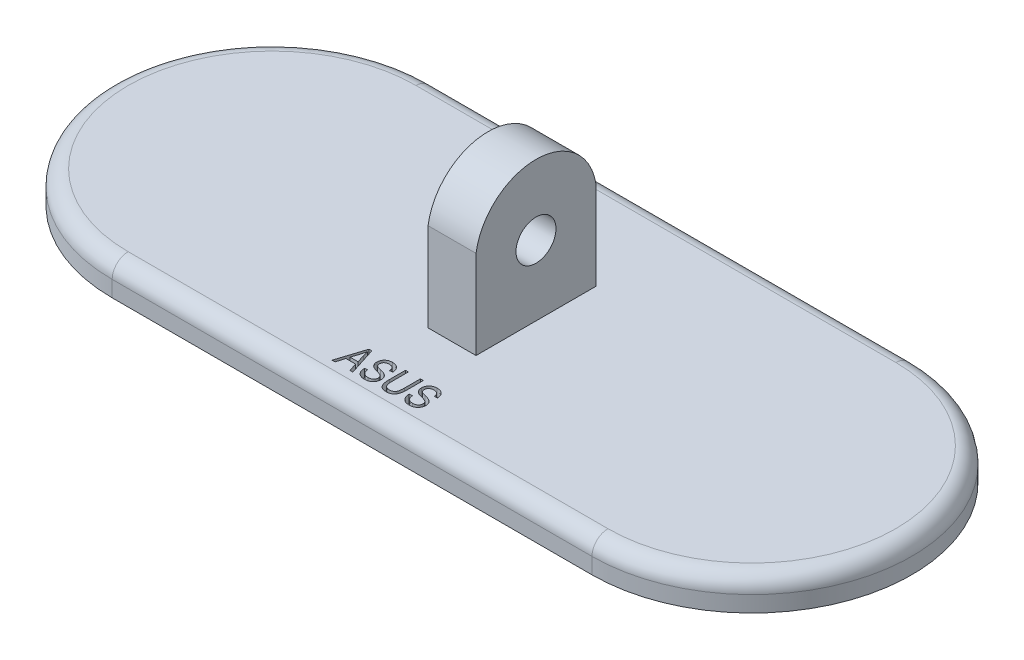
from build123d import *

# Parameters (mm, degrees)
BOSS_EXTRUDE1_DEPTH = 4
FILLET1_R           = 2
CUT_EXTRUDE1_DEPTH  = 1
SKETCH3_W           = 6
SKETCH3_H           = 15
BOSS_EXTRUDE2_DEPTH = 17.5
SKETCH4_R           = 2.5
CUT_EXTRUDE2_DEPTH  = 54


with BuildPart() as part:
    # Sketch1 → Boss-Extrude1 (new body)
    with BuildSketch(Plane(origin=(0, 0, 0), x_dir=(1, 0, 0), z_dir=(0, 1, 0))):
        with BuildLine():
            Line((-30, 20), (30, 20))
            ThreePointArc((30, 20), (50, 0), (30, -20))
            Line((30, -20), (-30, -20))
            ThreePointArc((-30, -20), (-50, 0), (-30, 20))
        make_face()
    extrude(amount=BOSS_EXTRUDE1_DEPTH)

    # Fillet1
    fillet1_edges = [part.edges().sort_by_distance(p)[0] for p in [
        (50, 4, 0),
        (0, 4, -20),
        (-50, 4, 0),
        (0, 4, 20),
    ]]
    fillet(fillet1_edges, radius=FILLET1_R)

    # Sketch2 → Cut-Extrude1 (cut)
    with BuildSketch(Plane(origin=(0, 4, 0), x_dir=(1, 0, 0), z_dir=(0, 1, 0))):
        Polygon((-5.5, -17), (-4.382102273, -13.5), (-4.027698864, -13.5), (-2.909090909, -17), (-3.286931818, -17), (-3.593039773, -15.954545455), (-4.816051136, -15.954545455), (-5.121448864, -17), align=None)
        with BuildLine():
            Line((-4.696732955, -15.545454545), (-3.713068182, -15.545454545))
            Line((-3.713068182, -15.545454545), (-4.005681818, -14.583806818))
            add(Edge.make_bspline(
                [(-4.005681818, -14.583806818), (-4.016628568, -14.547838767), (-4.0380005, -14.477616389), (-4.068265106, -14.374789216), (-4.09731225, -14.277259564), (-4.122124108, -14.184347112), (-4.146796541, -14.097260742), (-4.168074835, -14.015031326), (-4.18717565, -13.938066961), (-4.198909027, -13.888268538), (-4.204545455, -13.864346591)],
                knots=[0, 0, 0, 0, 0.00011279, 0.000220206, 0.000321569, 0.000418058, 0.000508692, 0.000593102, 0.000672856, 0.000746587, 0.000746587, 0.000746587, 0.000746587], degree=3))
            add(Edge.make_bspline(
                [(-4.204545455, -13.864346591), (-4.214778004, -13.920067319), (-4.235229509, -14.031434756), (-4.27356505, -14.197337197), (-4.316214502, -14.36294026), (-4.350161894, -14.472194468), (-4.3671875, -14.526988636)],
                knots=[0, 0, 0, 0, 0.000169936, 0.000339646, 0.000510706, 0.000682816, 0.000682816, 0.000682816, 0.000682816], degree=3))
            Line((-4.3671875, -14.526988636), (-4.696732955, -15.545454545))
        make_face(mode=Mode.SUBTRACT)
        with BuildLine():
            Line((-2.590909091, -15.863636364), (-2.227272727, -15.818181818))
            add(Edge.make_bspline(
                [(-2.227272727, -15.818181818), (-2.22197797, -15.864475668), (-2.211936421, -15.95227231), (-2.184434304, -16.075223938), (-2.147650136, -16.182043631), (-2.102205699, -16.274883356), (-2.043969166, -16.353580019), (-1.977448033, -16.424354515), (-1.899095683, -16.486099213), (-1.811387696, -16.540002711), (-1.714850911, -16.58350722), (-1.611278133, -16.613567605), (-1.502131405, -16.632807195), (-1.427403021, -16.63516064), (-1.389204545, -16.636363636)],
                knots=[0, 0, 0, 0, 0.00013972, 0.00026498, 0.000377063, 0.000478068, 0.000573677, 0.000669632, 0.000768682, 0.000871976, 0.000977838, 0.001085254, 0.001194776, 0.001309301, 0.001309301, 0.001309301, 0.001309301], degree=3))
            add(Edge.make_bspline(
                [(-1.389204545, -16.636363636), (-1.361956661, -16.635809911), (-1.309002617, -16.634733791), (-1.231895402, -16.626639835), (-1.159268353, -16.61444724), (-1.091804433, -16.595479121), (-1.028249477, -16.573297881), (-0.970392644, -16.543725979), (-0.91625106, -16.510305453), (-0.867397151, -16.471395087), (-0.824318723, -16.42766111), (-0.785271107, -16.3817624), (-0.753522436, -16.331514605), (-0.726751017, -16.278898951), (-0.707118518, -16.222620133), (-0.691891008, -16.163798809), (-0.683401716, -16.10133582), (-0.6823543, -16.058736303), (-0.681818182, -16.036931818)],
                knots=[0, 0, 0, 0, 8.1726e-05, 0.000158827, 0.000232389, 0.000302342, 0.000368846, 0.000433959, 0.000496821, 0.00055949, 0.00062076, 0.000680777, 0.00073988, 0.00079864, 0.000857499, 0.000918305, 0.00098068, 0.001046083, 0.001046083, 0.001046083, 0.001046083], degree=3))
            add(Edge.make_bspline(
                [(-0.681818182, -16.036931818), (-0.682599913, -16.011783639), (-0.684122535, -15.962801096), (-0.697082564, -15.891495502), (-0.71918005, -15.825416047), (-0.749262653, -15.764056888), (-0.788115011, -15.707910777), (-0.836096444, -15.65725245), (-0.893110954, -15.612473062), (-0.947513747, -15.578513088), (-1.000067739, -15.553778017), (-1.049719672, -15.532456693), (-1.109516389, -15.509966234), (-1.179361005, -15.485759378), (-1.259275635, -15.460541052), (-1.349304319, -15.433520449), (-1.449132376, -15.404343325), (-1.519382908, -15.385073654), (-1.556107955, -15.375)],
                knots=[0, 0, 0, 0, 7.5405e-05, 0.00014687, 0.000216494, 0.000283831, 0.000351209, 0.000420542, 0.000492307, 0.000568195, 0.000612349, 0.000666439, 0.00073028, 0.000803952, 0.000888182, 0.000981652, 0.001085942, 0.001200185, 0.001200185, 0.001200185, 0.001200185], degree=3))
            add(Edge.make_bspline(
                [(-1.556107955, -15.375), (-1.589066208, -15.365700823), (-1.652581841, -15.347779877), (-1.743664959, -15.319099389), (-1.82756541, -15.291259739), (-1.903766036, -15.261557906), (-1.97322383, -15.233349826), (-2.034571413, -15.203078327), (-2.088748272, -15.173437558), (-2.151054144, -15.134115412), (-2.219107276, -15.079119687), (-2.291234164, -15.005632486), (-2.354241661, -14.924260179), (-2.406810118, -14.835009875), (-2.449445591, -14.738977453), (-2.477677497, -14.635461447), (-2.497368172, -14.526552275), (-2.499111693, -14.451560064), (-2.5, -14.413352273)],
                knots=[0, 0, 0, 0, 0.000102728, 0.000197973, 0.000286464, 0.000367846, 0.000443294, 0.000511268, 0.00057294, 0.000628501, 0.000732099, 0.000834554, 0.000936837, 0.001040006, 0.001144643, 0.001250981, 0.001361203, 0.001475691, 0.001475691, 0.001475691, 0.001475691], degree=3))
            add(Edge.make_bspline(
                [(-2.5, -14.413352273), (-2.499216155, -14.378981672), (-2.497675273, -14.311415996), (-2.48452108, -14.21252492), (-2.463670739, -14.118103929), (-2.432557894, -14.0291615), (-2.394492747, -13.944430912), (-2.346286998, -13.86561284), (-2.29054503, -13.790818473), (-2.226008678, -13.721825566), (-2.154927099, -13.658551838), (-2.076487147, -13.604167759), (-1.992344651, -13.558082631), (-1.902482024, -13.519144857), (-1.806073101, -13.490352621), (-1.70403432, -13.470085913), (-1.596229432, -13.456768002), (-1.522294789, -13.455298921), (-1.484375, -13.454545455)],
                knots=[0, 0, 0, 0, 0.000103071, 0.000202617, 0.000298758, 0.000392642, 0.000484808, 0.000576891, 0.000669221, 0.000764203, 0.000859812, 0.000954187, 0.001049867, 0.001147228, 0.001247433, 0.001351063, 0.001459067, 0.001572783, 0.001572783, 0.001572783, 0.001572783], degree=3))
            add(Edge.make_bspline(
                [(-1.484375, -13.454545455), (-1.432677728, -13.45598872), (-1.331802768, -13.458804911), (-1.185476907, -13.482357844), (-1.049209402, -13.522259425), (-0.923518284, -13.577783176), (-0.809384889, -13.64787809), (-0.70876681, -13.732969255), (-0.620986799, -13.83115362), (-0.547962226, -13.94348761), (-0.48885885, -14.067402867), (-0.445580032, -14.202351051), (-0.417364879, -14.347607584), (-0.411900071, -14.448260029), (-0.409090909, -14.5)],
                knots=[0, 0, 0, 0, 0.000155027, 0.000302497, 0.00044318, 0.000579906, 0.000713536, 0.000843575, 0.000973865, 0.001107225, 0.001244144, 0.00138452, 0.001531332, 0.001686632, 0.001686632, 0.001686632, 0.001686632], degree=3))
            Line((-0.409090909, -14.5), (-0.772727273, -14.545454545))
            add(Edge.make_bspline(
                [(-0.772727273, -14.545454545), (-0.775394829, -14.517465857), (-0.78059677, -14.462885754), (-0.794969804, -14.384369508), (-0.813340355, -14.311163279), (-0.836372331, -14.243667328), (-0.865313417, -14.182131625), (-0.897535728, -14.125856233), (-0.935067643, -14.075422649), (-0.976941819, -14.030554018), (-1.023617894, -13.991261992), (-1.074471085, -13.956823707), (-1.129933758, -13.92765352), (-1.190104526, -13.904403902), (-1.254200278, -13.88569656), (-1.323001043, -13.873254871), (-1.396120547, -13.865306245), (-1.44647448, -13.864202485), (-1.472301136, -13.863636364)],
                knots=[0, 0, 0, 0, 8.4314e-05, 0.000164419, 0.000239178, 0.000310605, 0.000377968, 0.000442894, 0.000504827, 0.000566129, 0.000626603, 0.000687471, 0.000750056, 0.000814154, 0.000880688, 0.000950058, 0.001023627, 0.001101094, 0.001101094, 0.001101094, 0.001101094], degree=3))
            add(Edge.make_bspline(
                [(-1.472301136, -13.863636364), (-1.498607438, -13.863861681), (-1.549453941, -13.864297189), (-1.623406585, -13.872887979), (-1.692655981, -13.884233611), (-1.757296118, -13.901510812), (-1.816769957, -13.923315067), (-1.871904917, -13.949937896), (-1.921952204, -13.98162392), (-1.967182833, -14.018158832), (-2.006793971, -14.058783954), (-2.041640788, -14.101989157), (-2.071441238, -14.14794147), (-2.094667727, -14.197334209), (-2.113216893, -14.249432927), (-2.126849375, -14.30434261), (-2.134613493, -14.362230747), (-2.135772497, -14.40172917), (-2.136363636, -14.421875)],
                knots=[0, 0, 0, 0, 7.8864e-05, 0.000152433, 0.000223075, 0.000289229, 0.000352821, 0.000412856, 0.000472557, 0.000530125, 0.000586876, 0.000642447, 0.000696429, 0.000750751, 0.000805788, 0.000862115, 0.000920172, 0.000980608, 0.000980608, 0.000980608, 0.000980608], degree=3))
            add(Edge.make_bspline(
                [(-2.136363636, -14.421875), (-2.135158731, -14.45798656), (-2.132867659, -14.526651015), (-2.111448499, -14.623379604), (-2.075796294, -14.708163084), (-2.039637016, -14.754438968), (-2.022017045, -14.776988636)],
                knots=[0, 0, 0, 0, 0.000108188, 0.000205714, 0.000295712, 0.000381246, 0.000381246, 0.000381246, 0.000381246], degree=3))
            add(Edge.make_bspline(
                [(-2.022017045, -14.776988636), (-2.011198317, -14.787776882), (-1.9877006, -14.811208391), (-1.942444803, -14.840729621), (-1.888574861, -14.871786928), (-1.823291732, -14.899954833), (-1.748974666, -14.929489673), (-1.663747273, -14.956567477), (-1.568690497, -14.984584049), (-1.501258395, -15.001221491), (-1.465909091, -15.009943182)],
                knots=[0, 0, 0, 0, 4.5726e-05, 9.9314e-05, 0.000161332, 0.000232219, 0.000312277, 0.000401217, 0.000500336, 0.000609547, 0.000609547, 0.000609547, 0.000609547], degree=3))
            add(Edge.make_bspline(
                [(-1.465909091, -15.009943182), (-1.431077929, -15.018346165), (-1.364149902, -15.034492485), (-1.268169823, -15.059674797), (-1.179994991, -15.08295157), (-1.099756372, -15.10524418), (-1.028011119, -15.128309894), (-0.964125593, -15.149694435), (-0.907736501, -15.168790827), (-0.873737122, -15.183508799), (-0.857954545, -15.190340909)],
                knots=[0, 0, 0, 0, 0.000107489, 0.000206539, 0.000297673, 0.000381084, 0.000456332, 0.00052371, 0.000583238, 0.000634811, 0.000634811, 0.000634811, 0.000634811], degree=3))
            add(Edge.make_bspline(
                [(-0.857954545, -15.190340909), (-0.815377436, -15.210934727), (-0.732828012, -15.250862467), (-0.622785718, -15.329127409), (-0.528537774, -15.418058059), (-0.451846413, -15.519626488), (-0.39131779, -15.631595197), (-0.348919538, -15.754406993), (-0.322681069, -15.887146792), (-0.319709386, -15.979040994), (-0.318181818, -16.026278409)],
                knots=[0, 0, 0, 0, 0.000141677, 0.000274687, 0.000403287, 0.000529, 0.000654836, 0.000783544, 0.000917401, 0.001058993, 0.001058993, 0.001058993, 0.001058993], degree=3))
            add(Edge.make_bspline(
                [(-0.318181818, -16.026278409), (-0.31972652, -16.073750592), (-0.322778709, -16.167551257), (-0.349868593, -16.304755054), (-0.394130686, -16.435506064), (-0.45604135, -16.557681782), (-0.531806561, -16.670166003), (-0.620965754, -16.769947813), (-0.723916748, -16.854586795), (-0.839214384, -16.924475739), (-0.966866875, -16.979929102), (-1.107423102, -17.017296176), (-1.25981861, -17.041488087), (-1.365667813, -17.044101739), (-1.420454545, -17.045454545)],
                knots=[0, 0, 0, 0, 0.000142301, 0.000281173, 0.000417729, 0.000555261, 0.000690788, 0.000823556, 0.000955232, 0.001089096, 0.001226838, 0.001371229, 0.001524313, 0.001688561, 0.001688561, 0.001688561, 0.001688561], degree=3))
            add(Edge.make_bspline(
                [(-1.420454545, -17.045454545), (-1.463586734, -17.044550108), (-1.547753562, -17.042785216), (-1.670414663, -17.02758813), (-1.786247482, -17.002861618), (-1.895510013, -16.968015361), (-1.99836682, -16.923098139), (-2.094705237, -16.868313788), (-2.184047093, -16.803281539), (-2.265688913, -16.728457073), (-2.339520768, -16.645438235), (-2.404578332, -16.554918234), (-2.45960944, -16.456679389), (-2.504675468, -16.351522783), (-2.541329303, -16.239636899), (-2.568132253, -16.120769487), (-2.585265411, -15.99454887), (-2.58899827, -15.907960336), (-2.590909091, -15.863636364)],
                knots=[0, 0, 0, 0, 0.000129357, 0.000252423, 0.000370135, 0.000484236, 0.000595868, 0.000706249, 0.000816061, 0.000926661, 0.00103784, 0.001148804, 0.00126042, 0.001374941, 0.001491507, 0.001613147, 0.001740007, 0.001873049, 0.001873049, 0.001873049, 0.001873049], degree=3))
        make_face()
        with BuildLine():
            Line((2.045454545, -13.5), (2.409090909, -13.5))
            Line((2.409090909, -13.5), (2.409090909, -15.514204545))
            add(Edge.make_bspline(
                [(2.409090909, -15.514204545), (2.408923356, -15.555405357), (2.408595821, -15.635945022), (2.402965162, -15.754077177), (2.39653413, -15.866642424), (2.385857462, -15.973502622), (2.371597883, -16.074388511), (2.354581543, -16.169872597), (2.334896815, -16.25972689), (2.312330896, -16.344322046), (2.285343361, -16.423700996), (2.253194639, -16.498690113), (2.21637291, -16.569406789), (2.175188431, -16.636533443), (2.127211154, -16.697887468), (2.075071296, -16.755868641), (2.018444763, -16.809997481), (1.956298927, -16.859034292), (1.889812575, -16.903294034), (1.818054958, -16.940668757), (1.742868801, -16.973811945), (1.662600709, -16.999868994), (1.578360136, -17.020602312), (1.489443461, -17.034265103), (1.396529012, -17.044163368), (1.33288793, -17.045018409), (1.300426136, -17.045454545)],
                knots=[0, 0, 0, 0, 0.000123588, 0.00024159, 0.000354739, 0.000461805, 0.000563653, 0.000660337, 0.000752703, 0.000839536, 0.000922863, 0.001003997, 0.001084048, 0.001161892, 0.001239881, 0.001317325, 0.001395695, 0.001474559, 0.001554535, 0.001634916, 0.001716984, 0.001800757, 0.001887748, 0.001976954, 0.002070451, 0.002167793, 0.002167793, 0.002167793, 0.002167793], degree=3))
            add(Edge.make_bspline(
                [(1.300426136, -17.045454545), (1.255150549, -17.044694832), (1.167123779, -17.043217763), (1.039764185, -17.026228874), (0.920907741, -17.000444833), (0.810757778, -16.963469474), (0.709484059, -16.915766851), (0.616495335, -16.857900263), (0.53330225, -16.788476176), (0.457845097, -16.708456951), (0.391456252, -16.614302428), (0.335052614, -16.504173539), (0.28811466, -16.378041606), (0.248102928, -16.236598943), (0.218235521, -16.078756397), (0.197767834, -15.904785072), (0.183735999, -15.714952942), (0.182474335, -15.582887657), (0.181818182, -15.514204545)],
                knots=[0, 0, 0, 0, 0.000135744, 0.00026392, 0.000384711, 0.000500153, 0.000611668, 0.000719851, 0.000827792, 0.000935823, 0.001048935, 0.001172187, 0.001305938, 0.00145208, 0.00161268, 0.001787281, 0.001977391, 0.002183401, 0.002183401, 0.002183401, 0.002183401], degree=3))
            Line((0.181818182, -15.514204545), (0.181818182, -13.5))
            Line((0.181818182, -13.5), (0.545454545, -13.5))
            Line((0.545454545, -13.5), (0.545454545, -15.516335227))
            add(Edge.make_bspline(
                [(0.545454545, -15.516335227), (0.54576398, -15.55445341), (0.546361846, -15.628102411), (0.549878972, -15.734433564), (0.555551893, -15.832709771), (0.562931833, -15.922792134), (0.573655698, -16.004508095), (0.586284195, -16.078007075), (0.601078482, -16.143480587), (0.622902505, -16.218960871), (0.659507492, -16.301962092), (0.714489996, -16.390315237), (0.782017827, -16.465751895), (0.861012008, -16.528282263), (0.951010353, -16.576875772), (1.05026813, -16.611457225), (1.158684115, -16.632541867), (1.233802619, -16.635059209), (1.272727273, -16.636363636)],
                knots=[0, 0, 0, 0, 0.000114355, 0.000220949, 0.000319125, 0.000409661, 0.000492029, 0.000566291, 0.000633313, 0.000693313, 0.000801774, 0.000904236, 0.001004328, 0.001103934, 0.001204999, 0.001309675, 0.001418182, 0.001534875, 0.001534875, 0.001534875, 0.001534875], degree=3))
            add(Edge.make_bspline(
                [(1.272727273, -16.636363636), (1.305429116, -16.635724682), (1.368885859, -16.634484814), (1.460392807, -16.623763121), (1.545256708, -16.606367021), (1.622730089, -16.580587787), (1.693757602, -16.548770415), (1.757893228, -16.509566777), (1.814000439, -16.462138347), (1.86483847, -16.407855638), (1.907875946, -16.341897076), (1.945584423, -16.263971557), (1.976093475, -16.171850761), (2.002310261, -16.066974967), (2.021672499, -15.948165084), (2.035481282, -15.816324419), (2.044027275, -15.670803113), (2.044964436, -15.56937791), (2.045454545, -15.516335227)],
                knots=[0, 0, 0, 0, 9.8076e-05, 0.000190312, 0.000275979, 0.000357507, 0.000434743, 0.000509049, 0.000582161, 0.000654541, 0.000731364, 0.000817445, 0.000913576, 0.001021924, 0.001141487, 0.001274351, 0.001419488, 0.001578604, 0.001578604, 0.001578604, 0.001578604], degree=3))
            Line((2.045454545, -15.516335227), (2.045454545, -13.5))
        make_face()
        with BuildLine():
            Line((3, -15.863636364), (3.363636364, -15.818181818))
            add(Edge.make_bspline(
                [(3.363636364, -15.818181818), (3.368931121, -15.864475668), (3.37897267, -15.95227231), (3.406474787, -16.075223938), (3.443258955, -16.182043631), (3.488703392, -16.274883356), (3.546939925, -16.353580019), (3.613461058, -16.424354515), (3.691813407, -16.486099213), (3.779521395, -16.540002711), (3.87605818, -16.58350722), (3.979630958, -16.613567605), (4.088777686, -16.632807195), (4.16350607, -16.63516064), (4.201704545, -16.636363636)],
                knots=[0, 0, 0, 0, 0.00013972, 0.00026498, 0.000377063, 0.000478068, 0.000573677, 0.000669632, 0.000768682, 0.000871976, 0.000977838, 0.001085254, 0.001194776, 0.001309301, 0.001309301, 0.001309301, 0.001309301], degree=3))
            add(Edge.make_bspline(
                [(4.201704545, -16.636363636), (4.22895243, -16.635809911), (4.281906474, -16.634733791), (4.359013689, -16.626639835), (4.431640737, -16.61444724), (4.499104658, -16.595479121), (4.562659614, -16.573297881), (4.620516447, -16.543725979), (4.67465803, -16.510305453), (4.72351194, -16.471395087), (4.766590368, -16.42766111), (4.805637983, -16.3817624), (4.837386655, -16.331514605), (4.864158074, -16.278898951), (4.883790573, -16.222620133), (4.899018083, -16.163798809), (4.907507375, -16.10133582), (4.908554791, -16.058736303), (4.909090909, -16.036931818)],
                knots=[0, 0, 0, 0, 8.1726e-05, 0.000158827, 0.000232389, 0.000302342, 0.000368846, 0.000433959, 0.000496821, 0.00055949, 0.00062076, 0.000680777, 0.00073988, 0.00079864, 0.000857499, 0.000918305, 0.00098068, 0.001046083, 0.001046083, 0.001046083, 0.001046083], degree=3))
            add(Edge.make_bspline(
                [(4.909090909, -16.036931818), (4.908309178, -16.011783639), (4.906786556, -15.962801096), (4.893826527, -15.891495502), (4.871729041, -15.825416047), (4.841646438, -15.764056888), (4.80279408, -15.707910777), (4.754812647, -15.65725245), (4.697798137, -15.612473062), (4.643395344, -15.578513088), (4.590841352, -15.553778017), (4.541189419, -15.532456693), (4.481392702, -15.509966234), (4.411548086, -15.485759378), (4.331633456, -15.460541052), (4.241604772, -15.433520449), (4.141776715, -15.404343325), (4.071526182, -15.385073654), (4.034801136, -15.375)],
                knots=[0, 0, 0, 0, 7.5405e-05, 0.00014687, 0.000216494, 0.000283831, 0.000351209, 0.000420542, 0.000492307, 0.000568195, 0.000612349, 0.000666439, 0.00073028, 0.000803952, 0.000888182, 0.000981652, 0.001085942, 0.001200185, 0.001200185, 0.001200185, 0.001200185], degree=3))
            add(Edge.make_bspline(
                [(4.034801136, -15.375), (4.001842883, -15.365700823), (3.93832725, -15.347779877), (3.847244132, -15.319099389), (3.76334368, -15.291259739), (3.687143054, -15.261557906), (3.617685261, -15.233349826), (3.556337678, -15.203078327), (3.502160819, -15.173437558), (3.439854947, -15.134115412), (3.371801815, -15.079119687), (3.299674927, -15.005632486), (3.23666743, -14.924260179), (3.184098973, -14.835009875), (3.1414635, -14.738977453), (3.113231594, -14.635461447), (3.093540919, -14.526552275), (3.091797398, -14.451560064), (3.090909091, -14.413352273)],
                knots=[0, 0, 0, 0, 0.000102728, 0.000197973, 0.000286464, 0.000367846, 0.000443294, 0.000511268, 0.00057294, 0.000628501, 0.000732099, 0.000834554, 0.000936837, 0.001040006, 0.001144643, 0.001250981, 0.001361203, 0.001475691, 0.001475691, 0.001475691, 0.001475691], degree=3))
            add(Edge.make_bspline(
                [(3.090909091, -14.413352273), (3.091692936, -14.378981672), (3.093233818, -14.311415996), (3.106388011, -14.21252492), (3.127238351, -14.118103929), (3.158351197, -14.0291615), (3.196416344, -13.944430912), (3.244622093, -13.86561284), (3.300364061, -13.790818473), (3.364900413, -13.721825566), (3.435981992, -13.658551838), (3.514421944, -13.604167759), (3.59856444, -13.558082631), (3.688427067, -13.519144857), (3.78483599, -13.490352621), (3.886874771, -13.470085913), (3.994679659, -13.456768002), (4.068614302, -13.455298921), (4.106534091, -13.454545455)],
                knots=[0, 0, 0, 0, 0.000103071, 0.000202617, 0.000298758, 0.000392642, 0.000484808, 0.000576891, 0.000669221, 0.000764203, 0.000859812, 0.000954187, 0.001049867, 0.001147228, 0.001247433, 0.001351063, 0.001459067, 0.001572783, 0.001572783, 0.001572783, 0.001572783], degree=3))
            add(Edge.make_bspline(
                [(4.106534091, -13.454545455), (4.158231362, -13.45598872), (4.259106323, -13.458804911), (4.405432184, -13.482357844), (4.541699689, -13.522259425), (4.667390807, -13.577783176), (4.781524202, -13.64787809), (4.882142281, -13.732969255), (4.969922292, -13.83115362), (5.042946865, -13.94348761), (5.10205024, -14.067402867), (5.145329059, -14.202351051), (5.173544212, -14.347607584), (5.17900902, -14.448260029), (5.181818182, -14.5)],
                knots=[0, 0, 0, 0, 0.000155027, 0.000302497, 0.00044318, 0.000579906, 0.000713536, 0.000843575, 0.000973865, 0.001107225, 0.001244144, 0.00138452, 0.001531332, 0.001686632, 0.001686632, 0.001686632, 0.001686632], degree=3))
            Line((5.181818182, -14.5), (4.818181818, -14.545454545))
            add(Edge.make_bspline(
                [(4.818181818, -14.545454545), (4.815514262, -14.517465857), (4.810312321, -14.462885754), (4.795939287, -14.384369508), (4.777568736, -14.311163279), (4.75453676, -14.243667328), (4.725595674, -14.182131625), (4.693373363, -14.125856233), (4.655841448, -14.075422649), (4.613967272, -14.030554018), (4.567291197, -13.991261992), (4.516438006, -13.956823707), (4.460975333, -13.92765352), (4.400804565, -13.904403902), (4.336708813, -13.88569656), (4.267908048, -13.873254871), (4.194788543, -13.865306245), (4.144434611, -13.864202485), (4.118607955, -13.863636364)],
                knots=[0, 0, 0, 0, 8.4314e-05, 0.000164419, 0.000239178, 0.000310605, 0.000377968, 0.000442894, 0.000504827, 0.000566129, 0.000626603, 0.000687471, 0.000750056, 0.000814154, 0.000880688, 0.000950058, 0.001023627, 0.001101094, 0.001101094, 0.001101094, 0.001101094], degree=3))
            add(Edge.make_bspline(
                [(4.118607955, -13.863636364), (4.092301653, -13.863861681), (4.04145515, -13.864297189), (3.967502506, -13.872887979), (3.89825311, -13.884233611), (3.833612973, -13.901510812), (3.774139134, -13.923315067), (3.719004174, -13.949937896), (3.668956886, -13.98162392), (3.623726257, -14.018158832), (3.58411512, -14.058783954), (3.549268303, -14.101989157), (3.519467853, -14.14794147), (3.496241364, -14.197334209), (3.477692198, -14.249432927), (3.464059716, -14.30434261), (3.456295597, -14.362230747), (3.455136594, -14.40172917), (3.454545455, -14.421875)],
                knots=[0, 0, 0, 0, 7.8864e-05, 0.000152433, 0.000223075, 0.000289229, 0.000352821, 0.000412856, 0.000472557, 0.000530125, 0.000586876, 0.000642447, 0.000696429, 0.000750751, 0.000805788, 0.000862115, 0.000920172, 0.000980608, 0.000980608, 0.000980608, 0.000980608], degree=3))
            add(Edge.make_bspline(
                [(3.454545455, -14.421875), (3.45575036, -14.45798656), (3.458041432, -14.526651015), (3.479460592, -14.623379604), (3.515112797, -14.708163084), (3.551272075, -14.754438968), (3.568892045, -14.776988636)],
                knots=[0, 0, 0, 0, 0.000108188, 0.000205714, 0.000295712, 0.000381246, 0.000381246, 0.000381246, 0.000381246], degree=3))
            add(Edge.make_bspline(
                [(3.568892045, -14.776988636), (3.579710774, -14.787776882), (3.603208491, -14.811208391), (3.648464288, -14.840729621), (3.70233423, -14.871786928), (3.767617358, -14.899954833), (3.841934425, -14.929489673), (3.927161818, -14.956567477), (4.022218594, -14.984584049), (4.089650696, -15.001221491), (4.125, -15.009943182)],
                knots=[0, 0, 0, 0, 4.5726e-05, 9.9314e-05, 0.000161332, 0.000232219, 0.000312277, 0.000401217, 0.000500336, 0.000609547, 0.000609547, 0.000609547, 0.000609547], degree=3))
            add(Edge.make_bspline(
                [(4.125, -15.009943182), (4.159831162, -15.018346165), (4.226759189, -15.034492485), (4.322739268, -15.059674797), (4.4109141, -15.08295157), (4.491152719, -15.10524418), (4.562897972, -15.128309894), (4.626783498, -15.149694435), (4.68317259, -15.168790827), (4.717171969, -15.183508799), (4.732954545, -15.190340909)],
                knots=[0, 0, 0, 0, 0.000107489, 0.000206539, 0.000297673, 0.000381084, 0.000456332, 0.00052371, 0.000583238, 0.000634811, 0.000634811, 0.000634811, 0.000634811], degree=3))
            add(Edge.make_bspline(
                [(4.732954545, -15.190340909), (4.775531655, -15.210934727), (4.858081079, -15.250862467), (4.968123372, -15.329127409), (5.062371317, -15.418058059), (5.139062678, -15.519626488), (5.199591301, -15.631595197), (5.241989552, -15.754406993), (5.268228022, -15.887146792), (5.271199705, -15.979040994), (5.272727273, -16.026278409)],
                knots=[0, 0, 0, 0, 0.000141677, 0.000274687, 0.000403287, 0.000529, 0.000654836, 0.000783544, 0.000917401, 0.001058993, 0.001058993, 0.001058993, 0.001058993], degree=3))
            add(Edge.make_bspline(
                [(5.272727273, -16.026278409), (5.271182571, -16.073750592), (5.268130382, -16.167551257), (5.241040498, -16.304755054), (5.196778405, -16.435506064), (5.134867741, -16.557681782), (5.05910253, -16.670166003), (4.969943337, -16.769947813), (4.866992343, -16.854586795), (4.751694707, -16.924475739), (4.624042216, -16.979929102), (4.483485989, -17.017296176), (4.331090481, -17.041488087), (4.225241278, -17.044101739), (4.170454545, -17.045454545)],
                knots=[0, 0, 0, 0, 0.000142301, 0.000281173, 0.000417729, 0.000555261, 0.000690788, 0.000823556, 0.000955232, 0.001089096, 0.001226838, 0.001371229, 0.001524313, 0.001688561, 0.001688561, 0.001688561, 0.001688561], degree=3))
            add(Edge.make_bspline(
                [(4.170454545, -17.045454545), (4.127322357, -17.044550108), (4.043155529, -17.042785216), (3.920494428, -17.02758813), (3.804661609, -17.002861618), (3.695399078, -16.968015361), (3.592542271, -16.923098139), (3.496203854, -16.868313788), (3.406861998, -16.803281539), (3.325220178, -16.728457073), (3.251388323, -16.645438235), (3.186330758, -16.554918234), (3.131299651, -16.456679389), (3.086233623, -16.351522783), (3.049579788, -16.239636899), (3.022776838, -16.120769487), (3.00564368, -15.99454887), (3.001910821, -15.907960336), (3, -15.863636364)],
                knots=[0, 0, 0, 0, 0.000129357, 0.000252423, 0.000370135, 0.000484236, 0.000595868, 0.000706249, 0.000816061, 0.000926661, 0.00103784, 0.001148804, 0.00126042, 0.001374941, 0.001491507, 0.001613147, 0.001740007, 0.001873049, 0.001873049, 0.001873049, 0.001873049], degree=3))
        make_face()
    extrude(amount=-CUT_EXTRUDE1_DEPTH, mode=Mode.SUBTRACT)

    # Sketch3 → Boss-Extrude2 (add)
    with BuildSketch(Plane(origin=(0, 4, 0), x_dir=(1, 0, 0), z_dir=(0, 1, 0))):
        Rectangle(SKETCH3_W, SKETCH3_H)
    extrude(amount=BOSS_EXTRUDE2_DEPTH)

    # Sketch4 → Cut-Extrude2 (cut, through all)
    with BuildSketch(Plane.ZY.offset(3)):
        with Locations((0, 12.75)):
            Circle(SKETCH4_R)
        with BuildLine():
            Line((-7.5, 12.75), (-9.487224349, 12.75))
            Line((-9.487224349, 12.75), (-9.487224349, 22.792022481))
            Line((-9.487224349, 22.792022481), (9.037798836, 22.792022481))
            Line((9.037798836, 22.792022481), (9.037798836, 12.75))
            Line((9.037798836, 12.75), (7.5, 12.75))
            ThreePointArc((7.5, 12.75), (0, 21.5), (-7.5, 12.75))
        make_face()
    extrude(amount=-CUT_EXTRUDE2_DEPTH, mode=Mode.SUBTRACT)


solid = part.part
